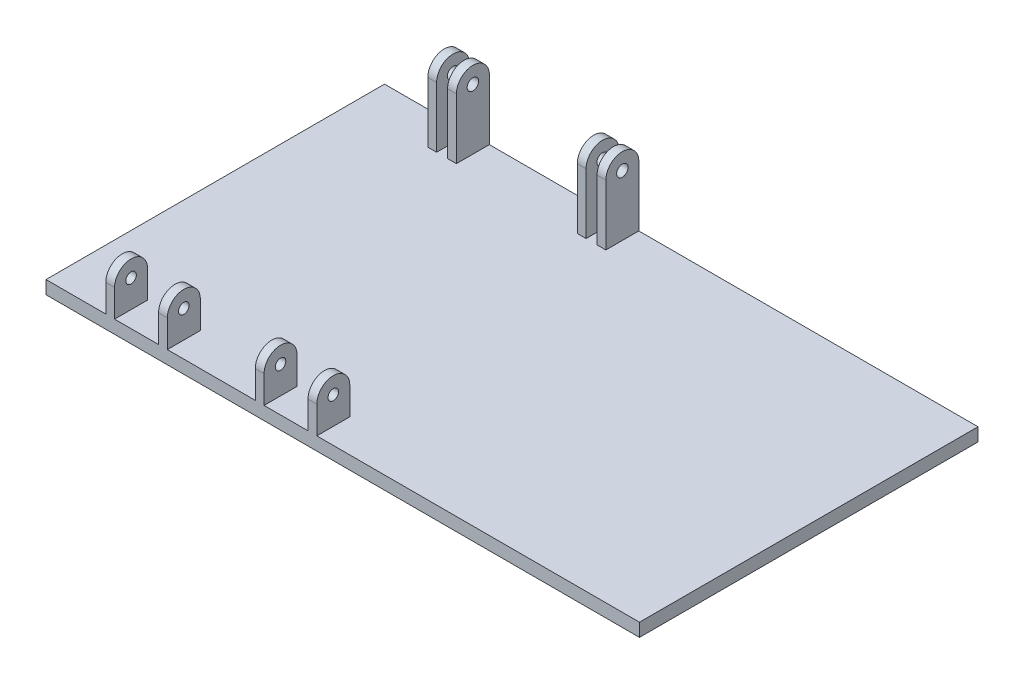
from build123d import *

# Parameters (mm, degrees)
SKETCH1_W           = 342.9
SKETCH1_H           = 195.58
BOSS_EXTRUDE1_DEPTH = 7.62
SKETCH2_W           = 5.08
SKETCH2_H           = 19.05
BOSS_EXTRUDE2_DEPTH = 25.4
SKETCH3_R           = 3.048
CUT_EXTRUDE1_DEPTH  = 367.63858527
SKETCH2_4_W         = 5.08
SKETCH2_4_H         = 19.05
BOSS_EXTRUDE3_DEPTH = 44.45
SKETCH4_R           = 3.302
CUT_EXTRUDE2_DEPTH  = 361.917448488


with BuildPart() as part:
    # Sketch1 → Boss-Extrude1 (new body)
    with BuildSketch(Plane(origin=(0, 0, 0), x_dir=(1, 0, 0), z_dir=(0, 1, 0))):
        with Locations((171.45, 97.79)):
            Rectangle(SKETCH1_W, SKETCH1_H)
    extrude(amount=BOSS_EXTRUDE1_DEPTH)

    # Sketch2 → Boss-Extrude2 (add)
    with BuildSketch(Plane(origin=(0, 7.62, 0), x_dir=(1, 0, 0), z_dir=(0, 1, 0))):
        with Locations((37.086314424, 9.525)):
            Rectangle(SKETCH2_W, SKETCH2_H)
        with Locations((153.926314424, 9.525)):
            Rectangle(SKETCH2_W, SKETCH2_H)
        with Locations((123.446314424, 9.525)):
            Rectangle(SKETCH2_W, SKETCH2_H)
        with Locations((67.566314424, 9.525)):
            Rectangle(SKETCH2_W, SKETCH2_H)
    extrude(amount=BOSS_EXTRUDE2_DEPTH)

    # Sketch3 → Cut-Extrude1 (cut, through all)
    with BuildSketch(Plane.ZY.offset(-34.546314424)):
        with Locations((-9.525, 23.495)):
            Circle(SKETCH3_R)
        with BuildLine():
            Line((-19.05, 23.495), (-20.422011891, 33.02))
            Line((-20.422011891, 33.02), (2.969055393, 35.880507904))
            Line((2.969055393, 35.880507904), (0, 23.495))
            ThreePointArc((0, 23.495), (-9.525, 33.02), (-19.05, 23.495))
        make_face()
    extrude(amount=-CUT_EXTRUDE1_DEPTH, mode=Mode.SUBTRACT)

    # Sketch2_4 → Boss-Extrude3 (add)
    with BuildSketch(Plane(origin=(0, 7.62, 0), x_dir=(1, 0, 0), z_dir=(0, 1, 0))):
        with Locations((46.611314424, 186.055)):
            Rectangle(SKETCH2_4_W, SKETCH2_4_H)
        with Locations((144.401314424, 186.055)):
            Rectangle(SKETCH2_4_W, SKETCH2_4_H)
        with Locations((132.971314424, 186.055)):
            Rectangle(SKETCH2_4_W, SKETCH2_4_H)
        with Locations((58.041314424, 186.055)):
            Rectangle(SKETCH2_4_W, SKETCH2_4_H)
    extrude(amount=BOSS_EXTRUDE3_DEPTH)

    # Sketch4 → Cut-Extrude2 (cut, through all)
    with BuildSketch(Plane.ZY.offset(-44.071314424)):
        with Locations((-186.055, 42.545)):
            Circle(SKETCH4_R)
        with BuildLine():
            Line((-195.58, 42.545), (-197.59428292, 55.074082425))
            Line((-197.59428292, 55.074082425), (-172.116639762, 54.451508438))
            Line((-172.116639762, 54.451508438), (-176.53, 42.545))
            ThreePointArc((-176.53, 42.545), (-186.055, 52.07), (-195.58, 42.545))
        make_face()
    extrude(amount=-CUT_EXTRUDE2_DEPTH, mode=Mode.SUBTRACT)


solid = part.part
